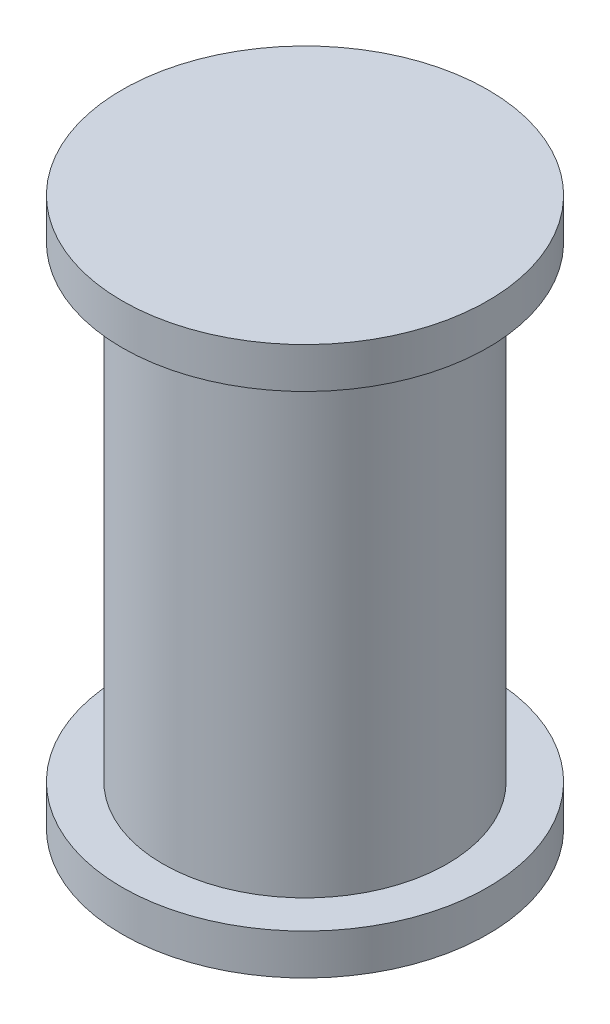
from build123d import *


with BuildPart() as part:
    # Sketch1 → Revolve1 (revolve)
    with BuildSketch(Plane(origin=(0, 0, 0), x_dir=(0, 0, -1), z_dir=(1, 0, 0))):
        Polygon((0, -5), (0, 0.4), (-1.8, 0.4), (-1.8, 0), (-1.4, 0), (-1.4, -4.6), (-1.8, -4.6), (-1.8, -5), align=None)
    revolve(axis=Axis((0, 0.4, 0), (0, -1, 0)))


solid = part.part
